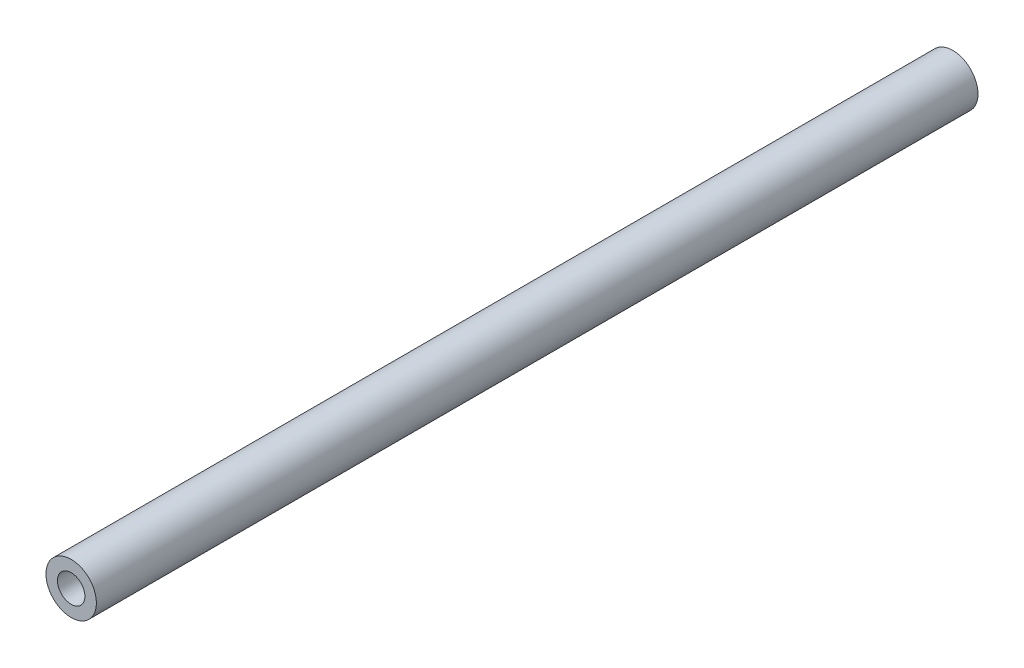
from build123d import *

# Parameters (mm, degrees)
BOSS_EXTRUDESHAFT_DEPTH                = 111
BOSS_EXTRUDESHAFT_DEPTH_BACK           = 111
SKETCH1_R                              = 6.35
F_5_16_24_TAPPED_HOLE2_D               = 6.9088
F_5_16_24_TAPPED_HOLE2_DEPTH           = 40
F_5_16_24_TAPPED_HOLE2_TIP             = 2.075612922
F_5_16_24_TAPPED_HOLE2_ON_FACE_2_D     = 6.9088
F_5_16_24_TAPPED_HOLE2_ON_FACE_2_DEPTH = 40
F_5_16_24_TAPPED_HOLE2_ON_FACE_2_TIP   = 2.075612922


with BuildPart() as part:
    # Sketch1 → Boss-ExtrudeShaft (new, two sides: drawn at the far end of the back side and taken through both)
    with BuildSketch(Plane.XY.offset(-BOSS_EXTRUDESHAFT_DEPTH_BACK)):
        Circle(SKETCH1_R)
    extrude(amount=BOSS_EXTRUDESHAFT_DEPTH + BOSS_EXTRUDESHAFT_DEPTH_BACK)

    # 5_16-24 Tapped Hole2
    with Locations(Plane(origin=(0, 0, -111), x_dir=(-1, 0, 0), z_dir=(0, 0, -1))):
        with Locations((0, 0)):
            Hole(F_5_16_24_TAPPED_HOLE2_D / 2, depth=F_5_16_24_TAPPED_HOLE2_DEPTH)
            with Locations((0, 0, -(F_5_16_24_TAPPED_HOLE2_DEPTH + F_5_16_24_TAPPED_HOLE2_TIP / 2))):  # 118° drill point
                Cone(0, F_5_16_24_TAPPED_HOLE2_D / 2, F_5_16_24_TAPPED_HOLE2_TIP, mode=Mode.SUBTRACT)

    # 5_16-24 Tapped Hole2 on face 2
    with Locations(Plane.XY.offset(111)):
        with Locations((0, 0)):
            Hole(F_5_16_24_TAPPED_HOLE2_ON_FACE_2_D / 2, depth=F_5_16_24_TAPPED_HOLE2_ON_FACE_2_DEPTH)
            with Locations((0, 0, -(F_5_16_24_TAPPED_HOLE2_ON_FACE_2_DEPTH + F_5_16_24_TAPPED_HOLE2_ON_FACE_2_TIP / 2))):  # 118° drill point
                Cone(0, F_5_16_24_TAPPED_HOLE2_ON_FACE_2_D / 2, F_5_16_24_TAPPED_HOLE2_ON_FACE_2_TIP, mode=Mode.SUBTRACT)


solid = part.part
